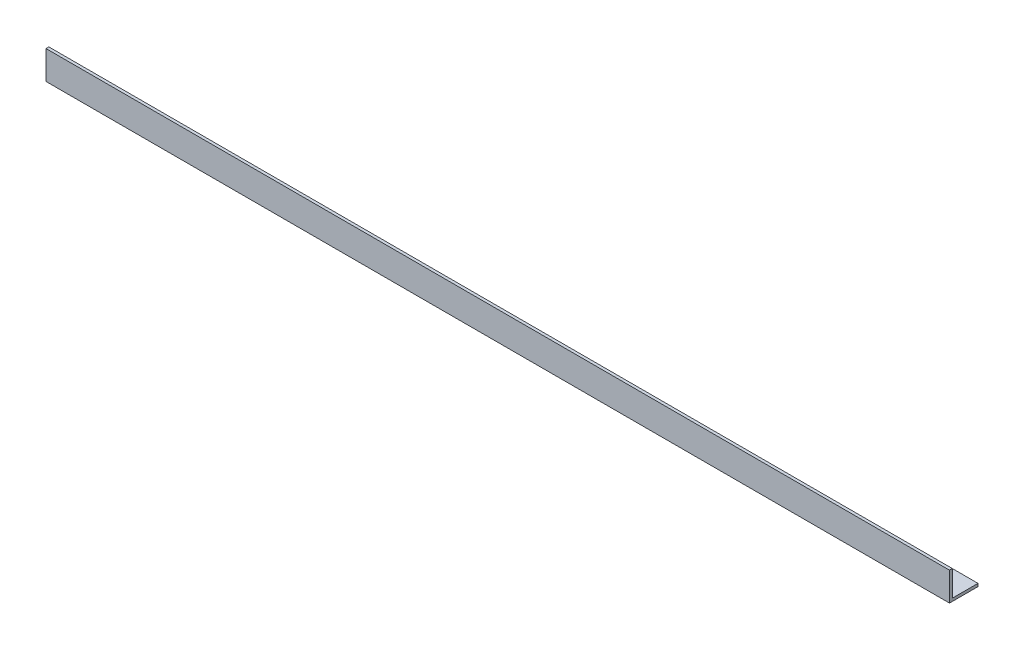
from build123d import *

# Parameters (mm, degrees)
EXTRUDE_1_DEPTH = 475


with BuildPart() as part:
    # Эскиз1 → Бобышка-Вытянуть1 (new body)
    with BuildSketch(Plane(origin=(0, 0, 0), x_dir=(0, 0, -1), z_dir=(1, 0, 0))):
        Polygon((0, 0), (0, 15), (1.5, 15), (1.5, 1.5), (15, 1.5), (15, 0), align=None)
    extrude(amount=EXTRUDE_1_DEPTH)


solid = part.part
